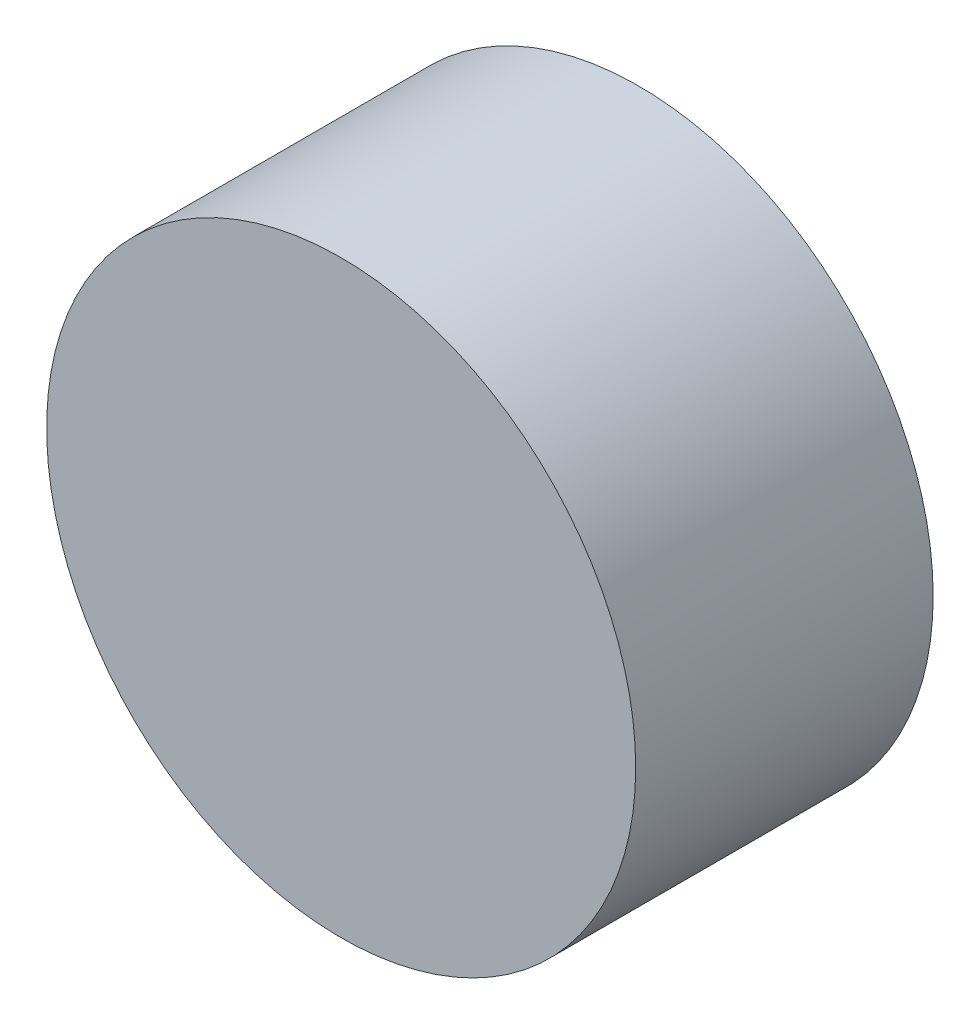
from build123d import *

# Parameters (mm, degrees)
SKETCH1_R           = 1.505
BOSS_EXTRUDE1_DEPTH = 1.52


with BuildPart() as part:
    # Sketch1 → Boss-Extrude1 (new body)
    with BuildSketch(Plane.XY):
        Circle(SKETCH1_R)
    extrude(amount=BOSS_EXTRUDE1_DEPTH)


solid = part.part
